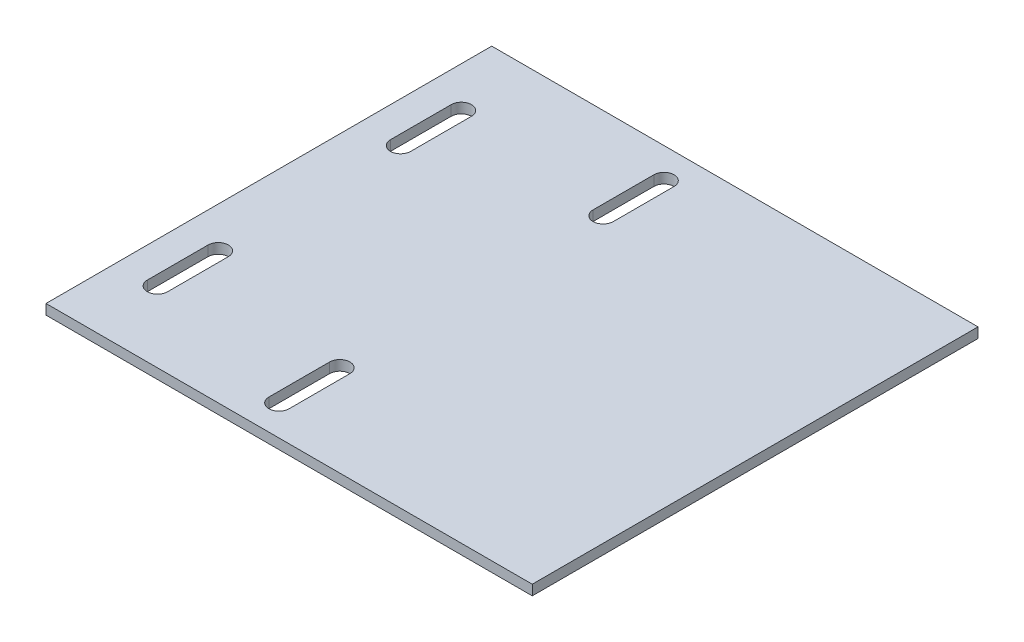
from build123d import *

# Parameters (mm, degrees)
SKETCH1_W           = 152.4
SKETCH1_H           = 139.7
BOSS_EXTRUDE1_DEPTH = 3.175
CUT_EXTRUDE1_DEPTH  = 4.175


with BuildPart() as part:
    # Sketch1 → Boss-Extrude1 (new body)
    with BuildSketch(Plane(origin=(0, 0, 0), x_dir=(1, 0, 0), z_dir=(0, 1, 0))):
        Rectangle(SKETCH1_W, SKETCH1_H)
    extrude(amount=BOSS_EXTRUDE1_DEPTH)

    # Sketch2 → Cut-Extrude1 (cut, through all)
    with BuildSketch(Plane(origin=(0, 3.175, 0), x_dir=(1, 0, 0), z_dir=(0, 1, 0))):
        with BuildLine():
            Line((-15.875, -41.275), (-15.875, -60.325))
            ThreePointArc((-15.875, -60.325), (-12.7, -63.5), (-9.525, -60.325))
            Line((-9.525, -60.325), (-9.525, -41.275))
            ThreePointArc((-9.525, -41.275), (-12.7, -38.1), (-15.875, -41.275))
        make_face()
        with BuildLine():
            Line((-9.525, 41.275), (-9.525, 60.325))
            ThreePointArc((-9.525, 60.325), (-12.7, 63.5), (-15.875, 60.325))
            Line((-15.875, 60.325), (-15.875, 41.275))
            ThreePointArc((-15.875, 41.275), (-12.7, 38.1), (-9.525, 41.275))
        make_face()
        with BuildLine():
            Line((-66.675, -28.575), (-66.675, -47.625))
            ThreePointArc((-66.675, -47.625), (-63.5, -50.8), (-60.325, -47.625))
            Line((-60.325, -47.625), (-60.325, -28.575))
            ThreePointArc((-60.325, -28.575), (-63.5, -25.4), (-66.675, -28.575))
        make_face()
        with BuildLine():
            Line((-66.675, 47.625), (-66.675, 28.575))
            ThreePointArc((-66.675, 28.575), (-63.5, 25.4), (-60.325, 28.575))
            Line((-60.325, 28.575), (-60.325, 47.625))
            ThreePointArc((-60.325, 47.625), (-63.5, 50.8), (-66.675, 47.625))
        make_face()
    extrude(amount=-CUT_EXTRUDE1_DEPTH, mode=Mode.SUBTRACT)


solid = part.part
